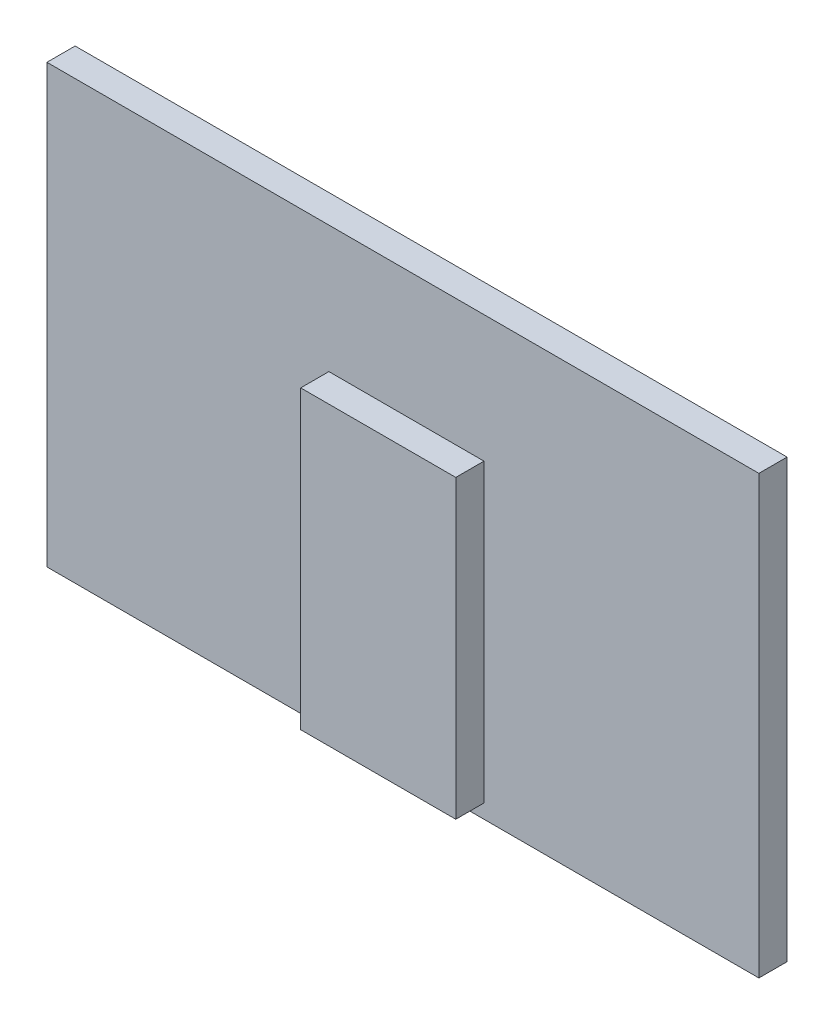
from build123d import *

# Parameters (mm, degrees)
SZKIC1_W                    = 505
SZKIC1_H                    = 310
DODANIE_WYCI_GNI_CIE1_DEPTH = 20
SZKIC2_W                    = 110
SZKIC2_H                    = 210
DODANIE_WYCI_GNI_CIE2_DEPTH = 20


with BuildPart() as part:
    # Szkic1 → Dodanie-wyciągnięcie1 (new body)
    with BuildSketch(Plane.XY):
        with Locations((-80.427502245, 23.25)):
            Rectangle(SZKIC1_W, SZKIC1_H)
    extrude(amount=DODANIE_WYCI_GNI_CIE1_DEPTH)

    # Szkic2 → Dodanie-wyciągnięcie2 (add)
    with BuildSketch(Plane.XY.offset(20)):
        with Locations((-77.927502245, -16.75)):
            Rectangle(SZKIC2_W, SZKIC2_H)
    extrude(amount=DODANIE_WYCI_GNI_CIE2_DEPTH)


solid = part.part
